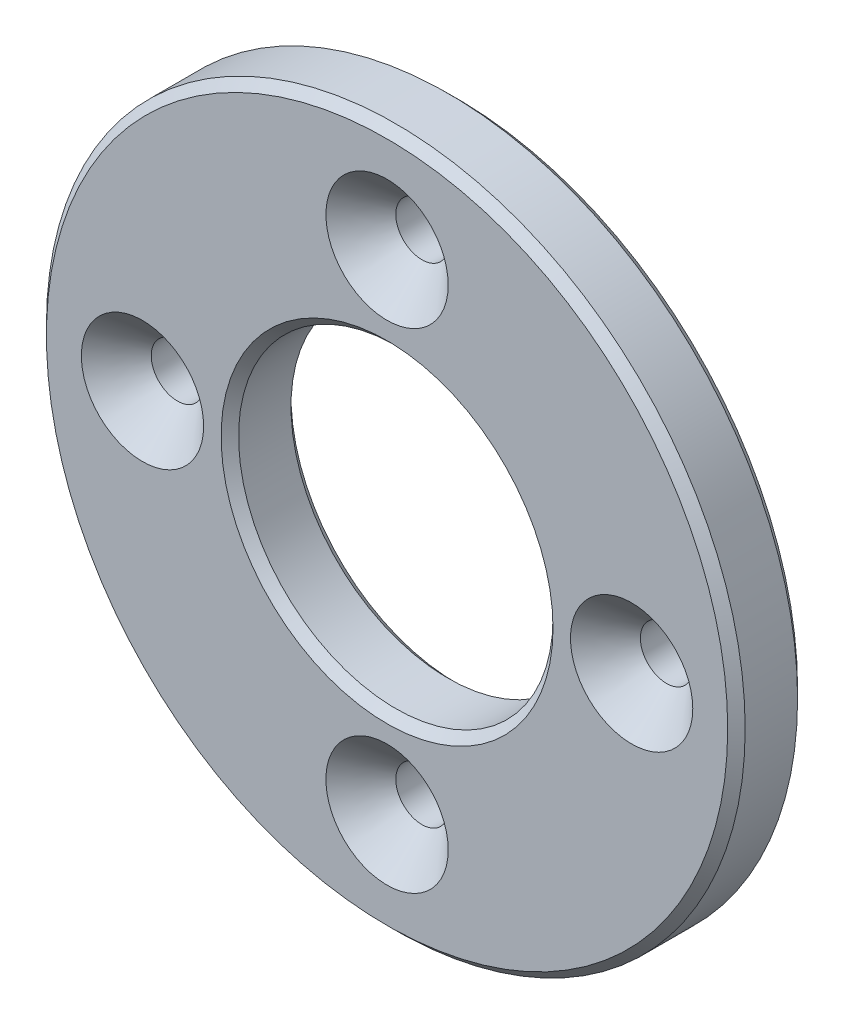
from build123d import *

# Parameters (mm, degrees)
ESQUISSE1_R      = 20
ESQUISSE1_R_2    = 9
ESQUISSE1_R_3    = 1.5
EXTRUSION1_DEPTH = 4
CHANFREIN1_SIZE  = 2
CHANFREIN2_SIZE  = 0.5


with BuildPart() as part:
    # Esquisse1 → Extrusion1 (new body)
    with BuildSketch(Plane.XY):
        Circle(ESQUISSE1_R)
        Circle(ESQUISSE1_R_2, mode=Mode.SUBTRACT)
        with Locations((0, 14)):
            Circle(ESQUISSE1_R_3, mode=Mode.SUBTRACT)
        with Locations((-14, 0)):
            Circle(ESQUISSE1_R_3, mode=Mode.SUBTRACT)
        with Locations((14, 0)):
            Circle(ESQUISSE1_R_3, mode=Mode.SUBTRACT)
        with Locations((0, -14)):
            Circle(ESQUISSE1_R_3, mode=Mode.SUBTRACT)
    extrude(amount=EXTRUSION1_DEPTH)

    # Chanfrein1
    chanfrein1_edges = [part.edges().sort_by_distance(p)[0] for p in [
        (-15.5, 0, 4),
        (12.5, 0, 4),
        (-1.5, -14, 4),
        (-1.5, 14, 4),
    ]]
    chamfer(chanfrein1_edges, length=CHANFREIN1_SIZE)

    # Chanfrein2
    chanfrein2_edges = [part.edges().sort_by_distance(p)[0] for p in [
        (-20, 0, 0),
        (-20, 0, 4),
        (-9, 0, 0),
        (-9, 0, 4),
    ]]
    chamfer(chanfrein2_edges, length=CHANFREIN2_SIZE)


solid = part.part
